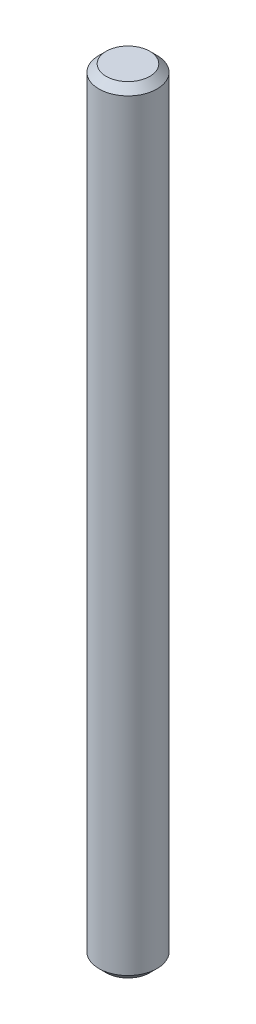
from build123d import *


with BuildPart() as part:
    # Sketch1 → Revolve1 (revolve)
    with BuildSketch(Plane.XY):
        Polygon((0, 26.7), (1.5, 26.7), (2, 26.2), (2, -26.2), (1.5, -26.7), (0, -26.7), align=None)
    revolve(axis=Axis((0, -26.7, 0), (0, 1, 0)))


solid = part.part
